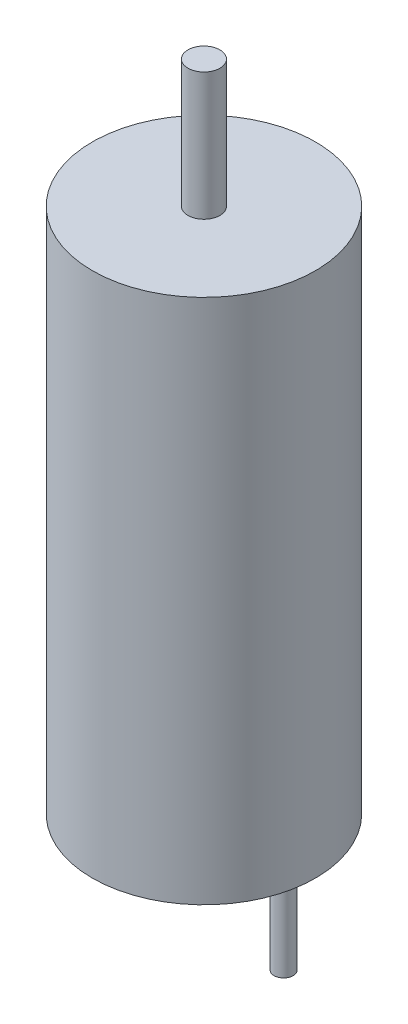
from build123d import *

# Parameters (mm, degrees)
SKETCH1_R           = 3.5
BOSS_EXTRUDE1_DEPTH = 16.5
SKETCH2_R           = 0.5
BOSS_EXTRUDE2_DEPTH = 4
SKETCH3_R           = 0.3
BOSS_EXTRUDE3_DEPTH = 3


with BuildPart() as part:
    # Sketch1 → Boss-Extrude1 (new body)
    with BuildSketch(Plane(origin=(0, 0, 0), x_dir=(1, 0, 0), z_dir=(0, 1, 0))):
        Circle(SKETCH1_R)
    extrude(amount=-BOSS_EXTRUDE1_DEPTH)

    # Sketch2 → Boss-Extrude2 (add)
    with BuildSketch(Plane(origin=(0, 0, 0), x_dir=(1, 0, 0), z_dir=(0, 1, 0))):
        Circle(SKETCH2_R)
    extrude(amount=BOSS_EXTRUDE2_DEPTH)

    # Sketch3 → Boss-Extrude3 (add)
    with BuildSketch(Plane.XZ.offset(16.5)):
        with Locations((2.5, 0)):
            Circle(SKETCH3_R)
        with Locations((-2.5, 0)):
            Circle(SKETCH3_R)
    extrude(amount=BOSS_EXTRUDE3_DEPTH)


solid = part.part
